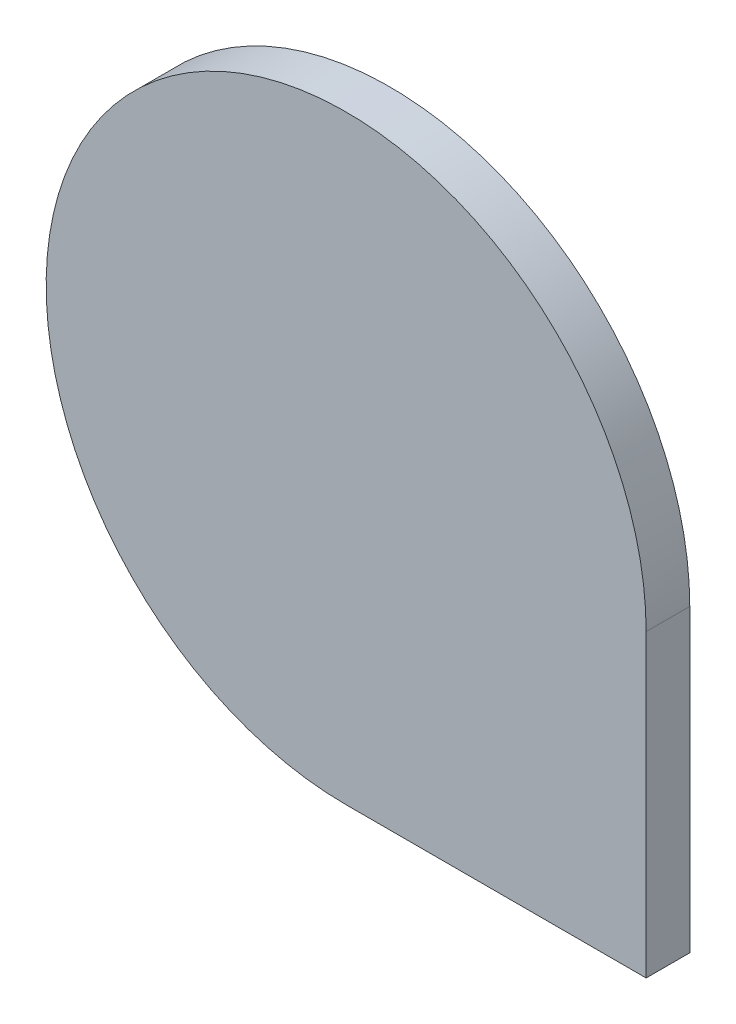
from build123d import *

# Parameters (mm, degrees)
BOSS_EXTRUDE1_DEPTH = 8


with BuildPart() as part:
    # Sketch1 → Boss-Extrude1 (new body)
    with BuildSketch(Plane.XY):
        with BuildLine():
            Line((55, 0), (55, -55))
            Line((55, -55), (0, -55))
            ThreePointArc((0, -55), (-38.890872965, 38.890872965), (55, 0))
        make_face()
    extrude(amount=BOSS_EXTRUDE1_DEPTH)


solid = part.part
